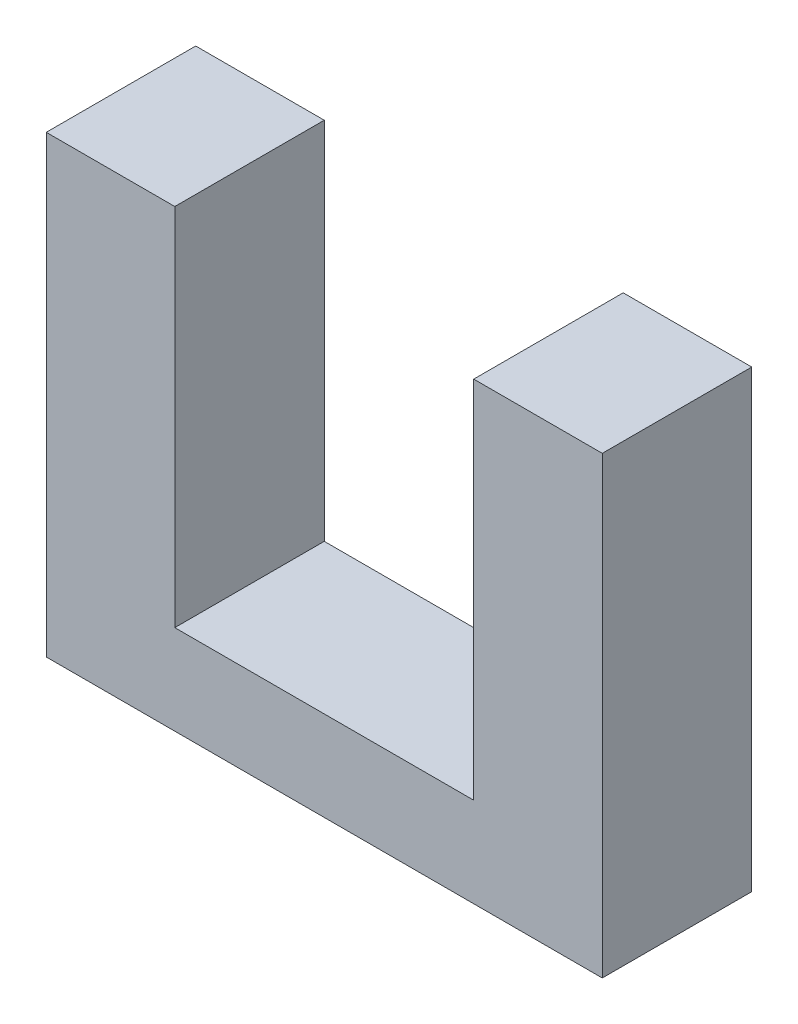
from build123d import *

# Parameters (mm, degrees)
BOSS_EXTRUDE1_DEPTH = 5


with BuildPart() as part:
    # Sketch1 → Boss-Extrude1 (new body)
    with BuildSketch(Plane.XY):
        Polygon((5, 0), (5, 12.2), (9.3, 12.2), (9.3, -3), (-9.3, -3), (-9.3, 12.2), (-5, 12.2), (-5, 0), align=None)
    extrude(amount=-BOSS_EXTRUDE1_DEPTH)


solid = part.part
